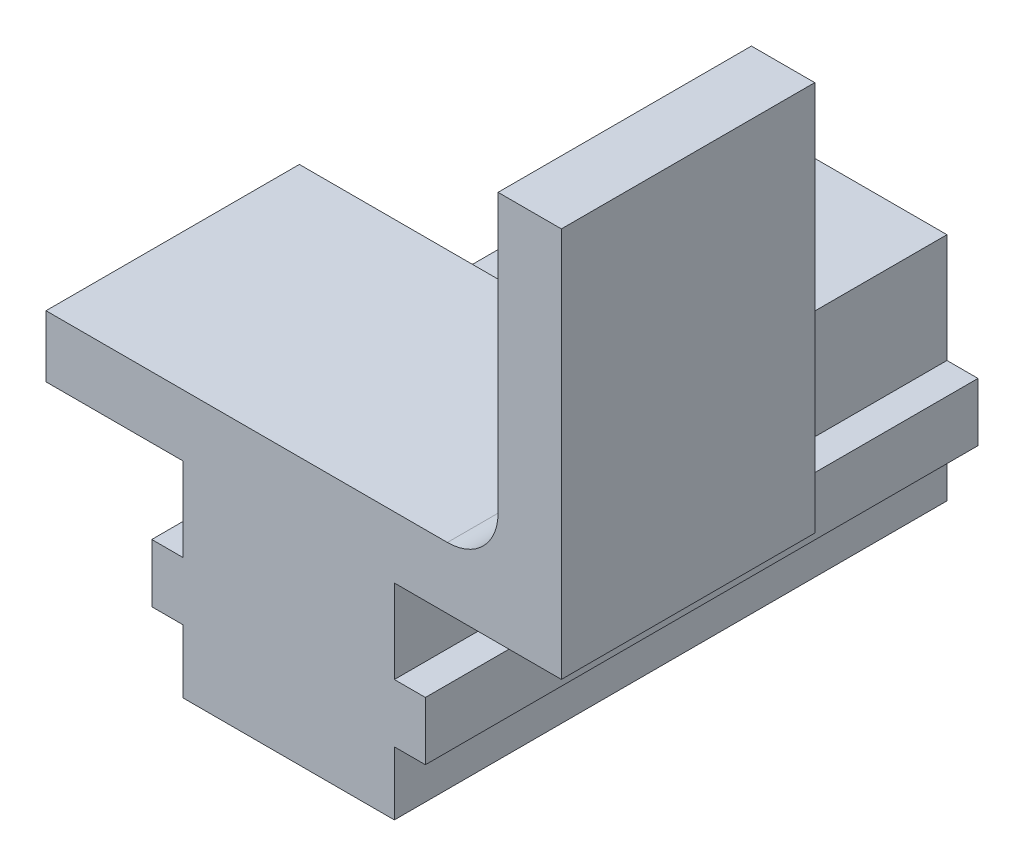
from build123d import *

# Parameters (mm, degrees)
BOSS_EXTRUDE1_DEPTH = 12.7
FILLET1_R           = 2.54
BOSS_EXTRUDE2_DEPTH = 15
FILLET2_R           = 1.27


with BuildPart() as part:
    # Sketch1 → Boss-Extrude1 (new body)
    with BuildSketch(Plane.XY):
        Polygon((0, 0), (0, -4.191), (-1.55575, -4.191), (-1.55575, -7.112), (0, -7.112), (0, -10.287), (10.6045, -10.287), (10.6045, -7.112), (12.16025, -7.112), (12.16025, -4.191), (10.6045, -4.191), (10.6045, 0), (18.97725, 0), (18.97725, 19.558), (15.80225, 19.558), (15.80225, 3.089), (-6.858, 3.089), (-6.858, 0), align=None)
    extrude(amount=BOSS_EXTRUDE1_DEPTH)

    # Fillet1
    fillet1_edges = [part.edges().sort_by_distance(p)[0] for p in [
        (15.80225, 3.089, 6.35),
    ]]
    fillet(fillet1_edges, radius=FILLET1_R)

    # Sketch2 → Boss-Extrude2 (add)
    with BuildSketch(Plane.XY):
        Polygon((0, 0), (0, 1.27), (10.6045, 1.27), (10.6045, 0), (10.6045, -4.191), (12.16025, -4.191), (12.16025, -7.112), (10.6045, -7.112), (10.6045, -10.287), (0, -10.287), (0, -7.112), (-1.55575, -7.112), (-1.55575, -4.191), (0, -4.191), align=None)
    extrude(amount=-BOSS_EXTRUDE2_DEPTH)

    # Fillet2
    fillet2_edges = [part.edges().sort_by_distance(p)[0] for p in [
        (5.30225, 1.27, 0),
    ]]
    fillet(fillet2_edges, radius=FILLET2_R)


solid = part.part
